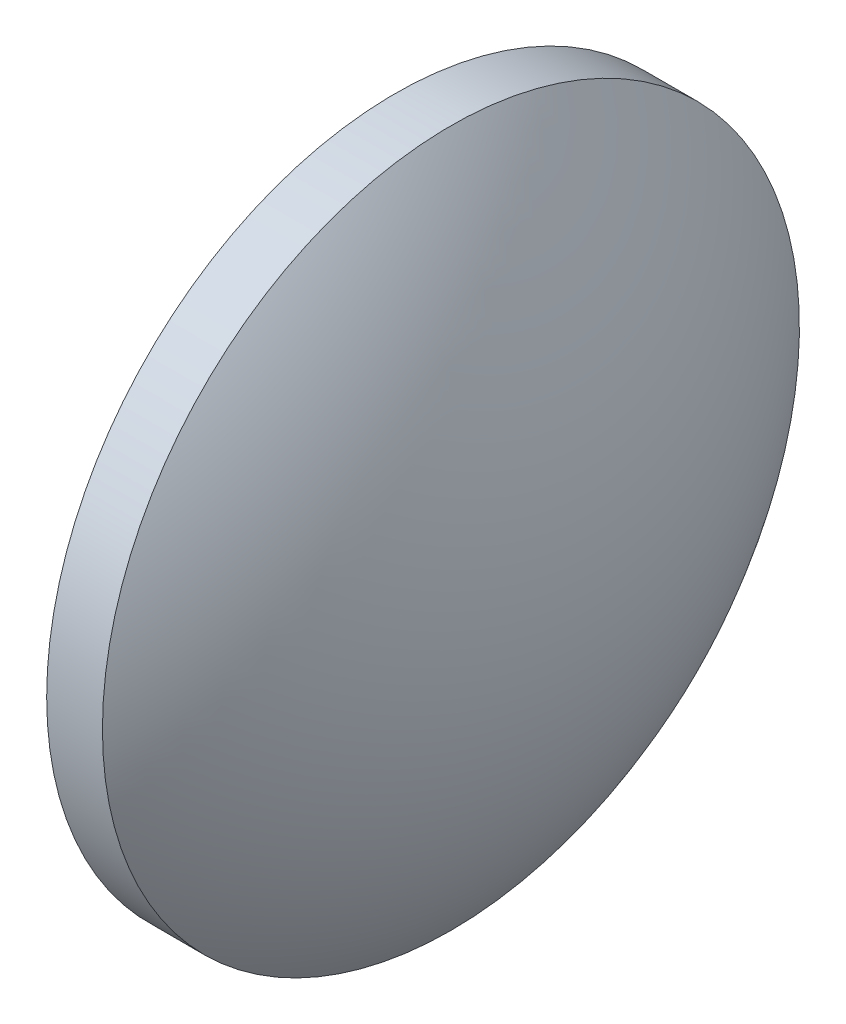
from build123d import *


with BuildPart() as part:
    # 草图1 → 旋转1 (revolve)
    with BuildSketch(Plane.XY, mode=Mode.PRIVATE) as revolve_1_sk:
        with BuildLine():
            Line((634.686585925, 47.946553126), (634.686585925, 60.446553126))
            Line((634.686585925, 60.446553126), (636.686585925, 60.446553126))
            ThreePointArc((636.686585925, 60.446553126), (639.815820167, 54.541515218), (640.896585925, 47.946553126))
            Line((640.896585925, 47.946553126), (634.686585925, 47.946553126))
        make_face()
    revolve(revolve_1_sk.sketch.rotate(Axis((632.657478347, 47.946553126, 0), (1, 0, 0)), 180), axis=Axis((632.657478347, 47.946553126, 0), (1, 0, 0)))  # turned: the seam where the file's is


solid = part.part
